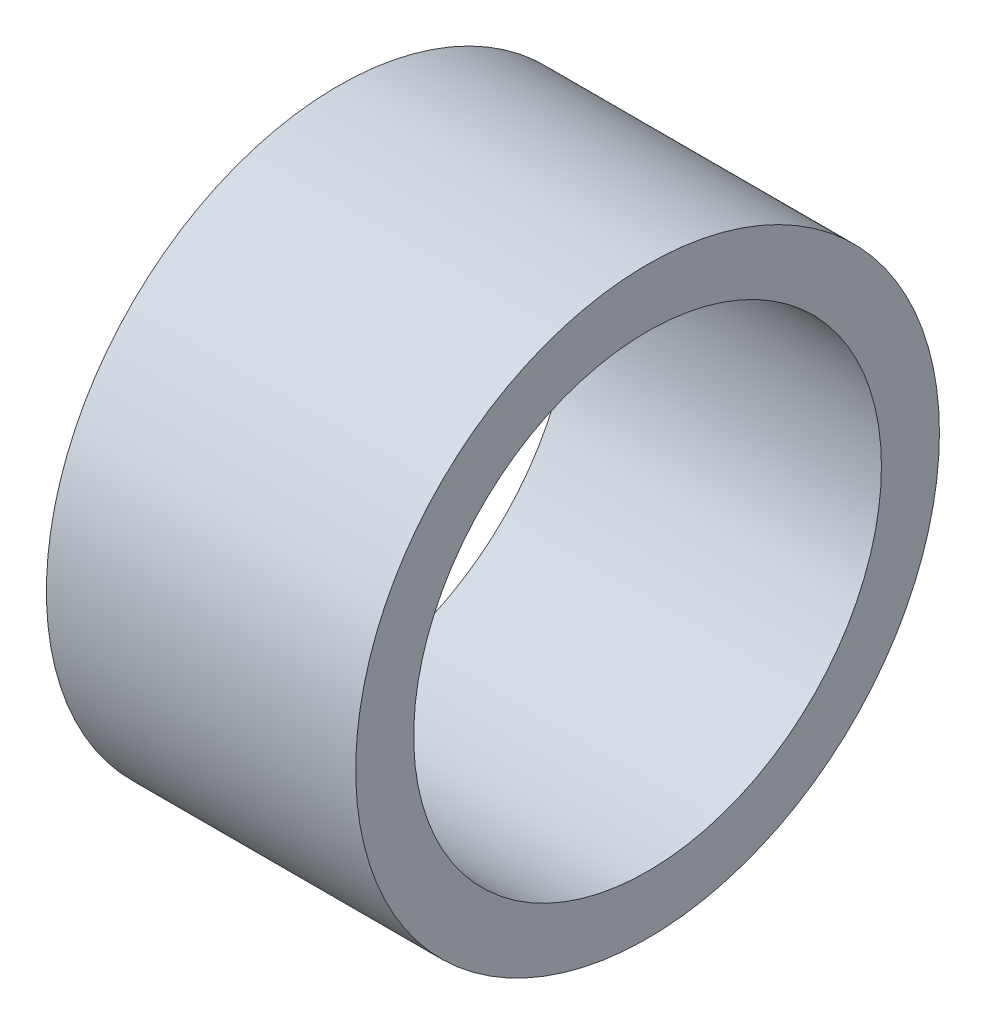
from build123d import *

# Parameters (mm, degrees)
SKETCH1_R           = 7.55
SKETCH1_R_2         = 6.05
BOSS_EXTRUDE1_DEPTH = 8


with BuildPart() as part:
    # Sketch1 → Boss-Extrude1 (new body)
    with BuildSketch(Plane(origin=(0, 0, 0), x_dir=(0, 0, -1), z_dir=(1, 0, 0))):
        Circle(SKETCH1_R)
        Circle(SKETCH1_R_2, mode=Mode.SUBTRACT)
    extrude(amount=BOSS_EXTRUDE1_DEPTH)


solid = part.part
